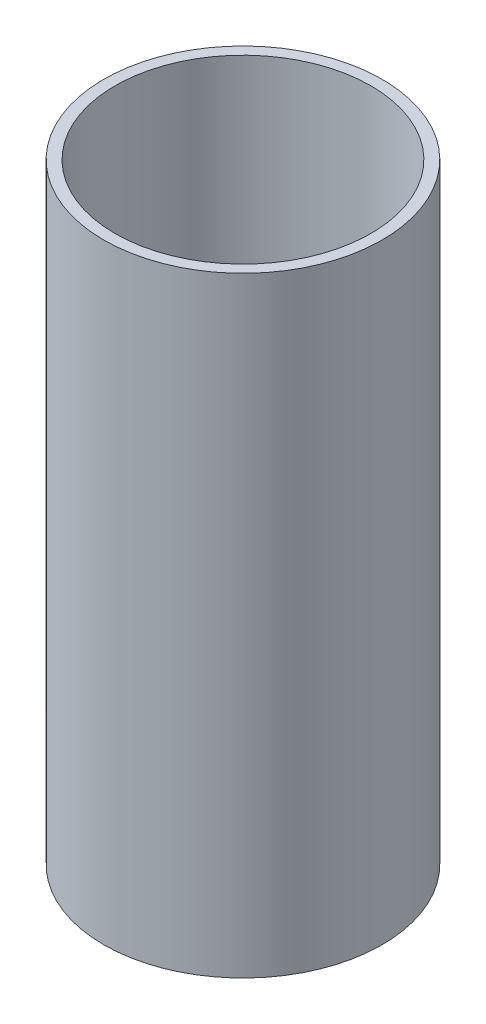
from build123d import *

# Parameters (mm, degrees)
CROQUIS3_W = 2.1
CROQUIS3_H = 114


with BuildPart() as part:
    # Croquis3 → Revolución1 (revolve)
    with BuildSketch(Plane.XY):
        with Locations((-24.95, -26.780088001)):
            Rectangle(CROQUIS3_W, CROQUIS3_H)
    revolve(axis=Axis((0, 30.219911999, 0), (0, -1, 0)))


solid = part.part
